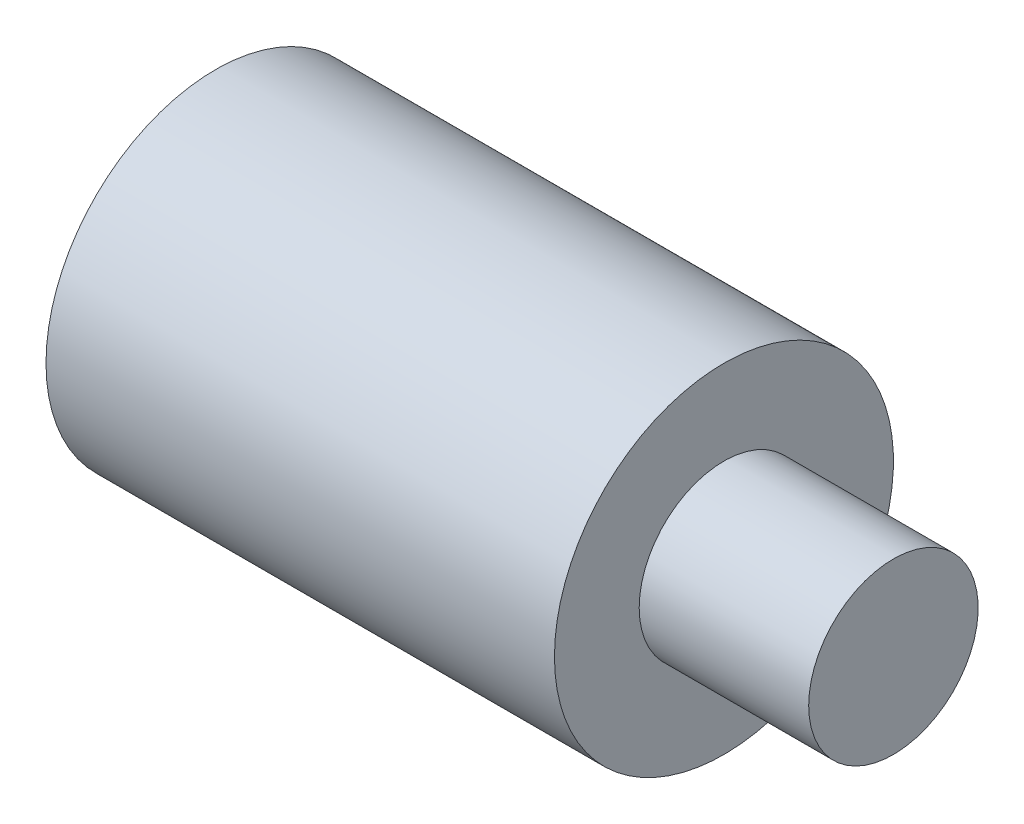
from build123d import *


with BuildPart() as part:
    # Sketch1 → Revolve1 (revolve)
    with BuildSketch(Plane.XY):
        Polygon((0, 0), (0, 6.35), (19.05, 6.35), (19.05, 3.175), (25.4, 3.175), (25.4, 0), align=None)
    revolve(axis=Axis((-27.566700925, 0, 0), (1, 0, 0)))


solid = part.part
